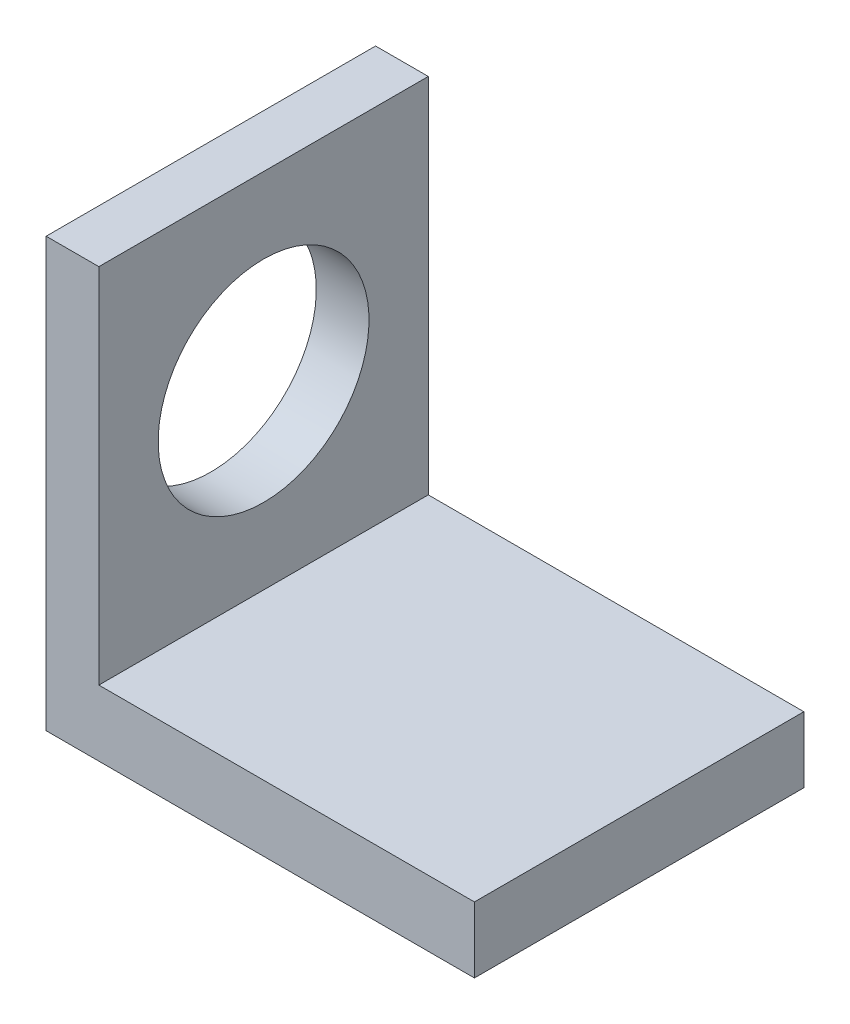
from build123d import *

# Parameters (mm, degrees)
AUFSATZ_LINEAR_AUSTRAGEN1_DEPTH = 50
SKIZZE2_R                       = 16
SCHNITT_LINEAR_AUSTRAGEN1_DEPTH = 50


with BuildPart() as part:
    # Skizze1 → Aufsatz-Linear austragen1 (new body)
    with BuildSketch(Plane.XY):
        Polygon((0, 65), (8, 65), (8, 10), (65, 10), (65, 0), (0, 0), align=None)
    extrude(amount=-AUFSATZ_LINEAR_AUSTRAGEN1_DEPTH)

    # Skizze2 → Schnitt-Linear austragen1 (cut)
    with BuildSketch(Plane(origin=(8, 0, 0), x_dir=(0, 0, -1), z_dir=(1, 0, 0))):
        with Locations((25, 37.5)):
            Circle(SKIZZE2_R)
    extrude(amount=-SCHNITT_LINEAR_AUSTRAGEN1_DEPTH, mode=Mode.SUBTRACT)


solid = part.part
